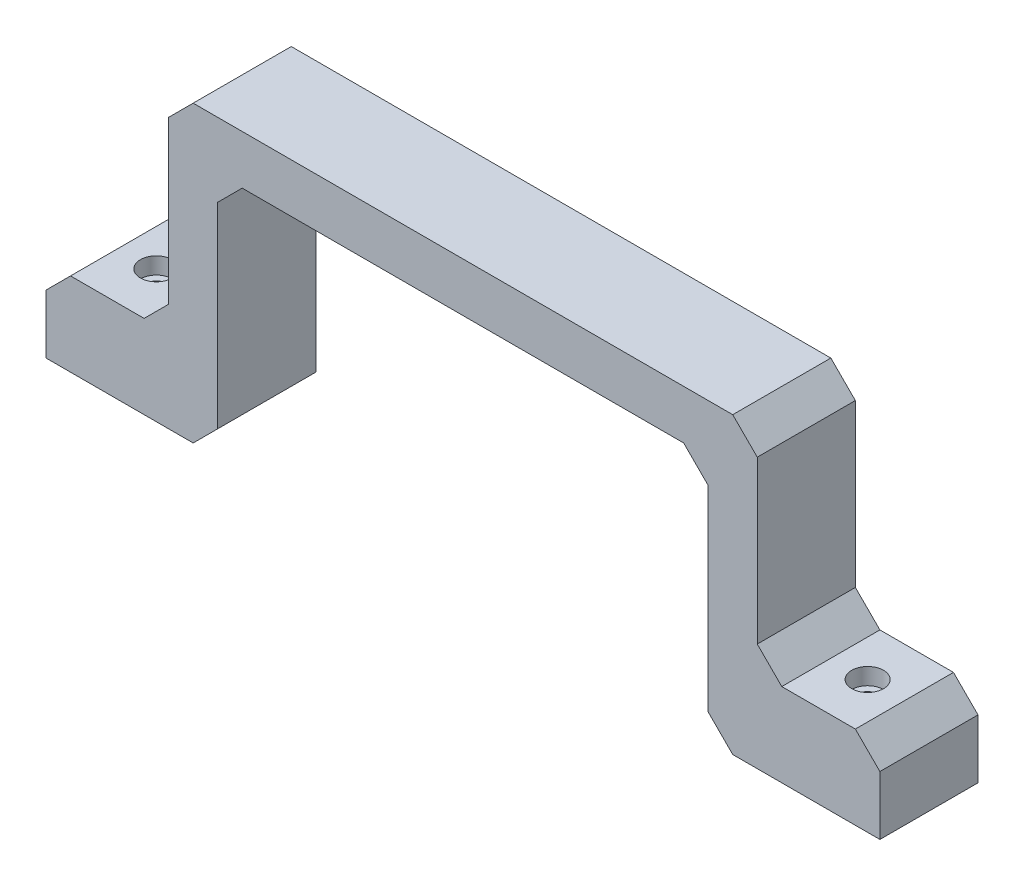
from build123d import *

# Parameters (mm, degrees)
AUFSATZ_LINEAR_AUSTRAGEN1_DEPTH                      = 20
STIRNSENKUNG_F_R_M3_ZYLINDERSCHRAUBE_MIT_D           = 3.6
STIRNSENKUNG_F_R_M3_ZYLINDERSCHRAUBE_MIT_DEPTH       = 17
STIRNSENKUNG_F_R_M3_ZYLINDERSCHRAUBE_MIT_CBORE_D     = 6.5
STIRNSENKUNG_F_R_M3_ZYLINDERSCHRAUBE_MIT_CBORE_DEPTH = 3.4


with BuildPart() as part:
    # Skizze1 → Aufsatz-Linear austragen1 (new body)
    with BuildSketch(Plane.XY):
        Polygon((5, 0), (20, 0), (25, 5), (25, 38), (30, 43), (140, 43), (145, 38), (145, 5), (150, 0), (165, 0), (170, -5), (170, -17), (140, -17), (135, -12), (135, 28), (130, 33), (40, 33), (35, 28), (35, -12), (30, -17), (0, -17), (0, -5), align=None)
    extrude(amount=AUFSATZ_LINEAR_AUSTRAGEN1_DEPTH)

    # Stirnsenkung für M3 Zylinderschraube mit Innensechskant2
    with Locations(Plane(origin=(0, 0, 0), x_dir=(1, 0, 0), z_dir=(0, 1, 0))):
        with Locations((157.5, -10), (12.5, -10)):
            CounterBoreHole(STIRNSENKUNG_F_R_M3_ZYLINDERSCHRAUBE_MIT_D / 2, STIRNSENKUNG_F_R_M3_ZYLINDERSCHRAUBE_MIT_CBORE_D / 2, STIRNSENKUNG_F_R_M3_ZYLINDERSCHRAUBE_MIT_CBORE_DEPTH, depth=STIRNSENKUNG_F_R_M3_ZYLINDERSCHRAUBE_MIT_DEPTH)


solid = part.part
